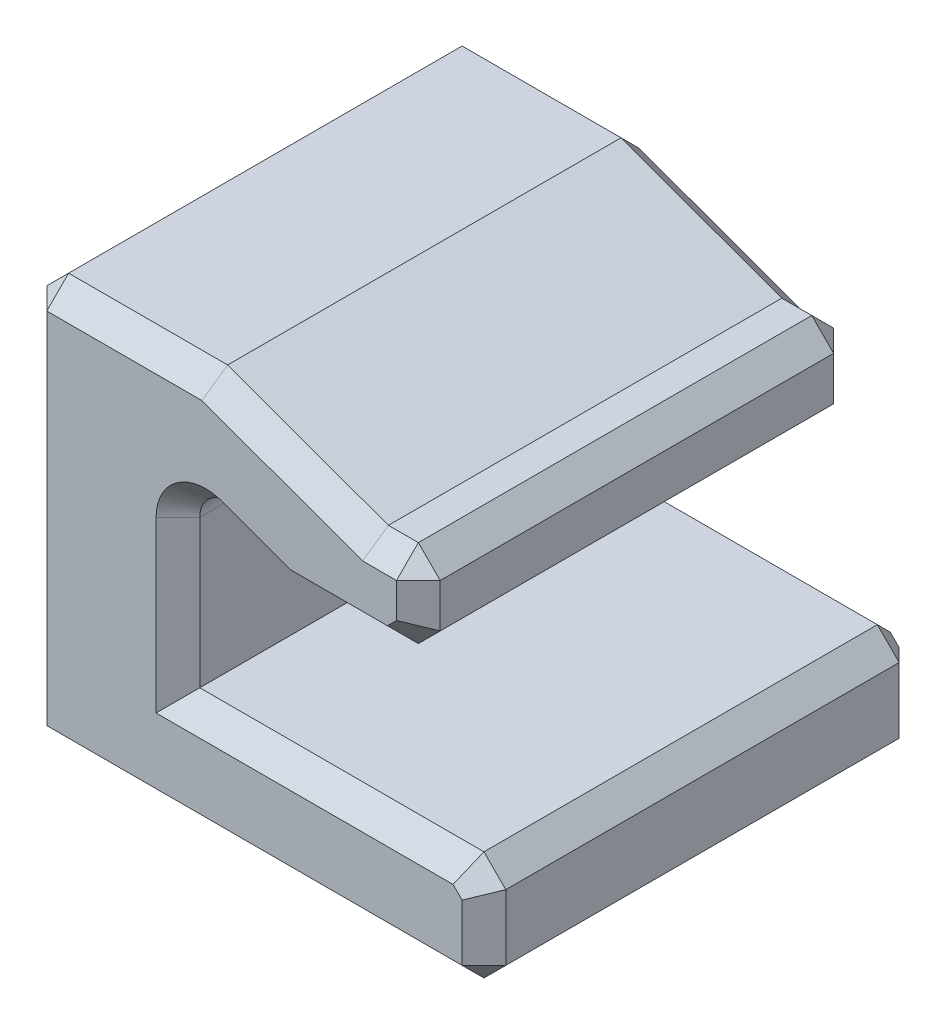
from build123d import *

# Parameters (mm, degrees)
BOSS_EXTRUDE1_DEPTH = 20
CHAMFER1_SIZE       = 1
CHAMFER2_SIZE       = 1


with BuildPart() as part:
    # Sketch1 → Boss-Extrude1 (new body)
    with BuildSketch(Plane.XY):
        with BuildLine():
            Line((0, 6.75), (0, 0))
            Line((0, 0), (14, 0))
            Line((14, 0), (14, -5))
            Line((14, -5), (-7, -5))
            Line((-7, -5), (-7, 13.426942406))
            Line((-7, 13.426942406), (1.274273509, 13.426942406))
            Line((1.274273509, 13.426942406), (8.629112323, 10.75))
            Line((8.629112323, 10.75), (11, 10.75))
            Line((11, 10.75), (11, 6.75))
            Line((11, 6.75), (5, 6.75))
            Line((5, 6.75), (1.710100717, 7.947425413))
            ThreePointArc((1.710100717, 7.947425413), (0.543380251, 7.79382375), (0, 6.75))
        make_face()
    extrude(amount=BOSS_EXTRUDE1_DEPTH)

    # Chamfer1
    chamfer1_edges = [part.edges().sort_by_distance(p)[0] for p in [
        (14, 0, 10),
        (11, 6.75, 10),
    ]]
    chamfer(chamfer1_edges, length=CHAMFER1_SIZE)

    # Chamfer2
    chamfer2_edges = [part.edges().sort_by_distance(p)[0] for p in [
        (6.5, 0, 0),
        (3.355050358, 7.348712706, 20),
        (3.5, -5, 0),
        (-7, 4.213471203, 0),
        (-2.862863246, 13.426942406, 0),
        (4.951692916, 12.088471203, 0),
        (9.814556161, 10.75, 0),
        (11, 9.25, 0),
        (3.355050358, 7.348712706, 0),
        (0.543380251, 7.79382375, 0),
        (0, 3.375, 0),
        (11, 9.25, 20),
        (14, -5, 10),
        (-7, -5, 10),
        (-7, 13.426942406, 10),
        (11, 10.75, 10),
        (9.814556161, 10.75, 20),
        (4.951692916, 12.088471203, 20),
        (-2.862863246, 13.426942406, 20),
        (-7, 4.213471203, 20),
        (14, -3, 0),
        (7.5, 6.75, 0),
        (10.5, 7.25, 0),
        (13.5, -0.5, 0),
        (14, -3, 20),
        (7.5, 6.75, 20),
        (10.5, 7.25, 20),
        (3.5, -5, 20),
        (13.5, -0.5, 20),
        (6.5, 0, 20),
        (0, 3.375, 20),
        (0.543380251, 7.79382375, 20),
    ]]
    chamfer(chamfer2_edges, length=CHAMFER2_SIZE)


solid = part.part
